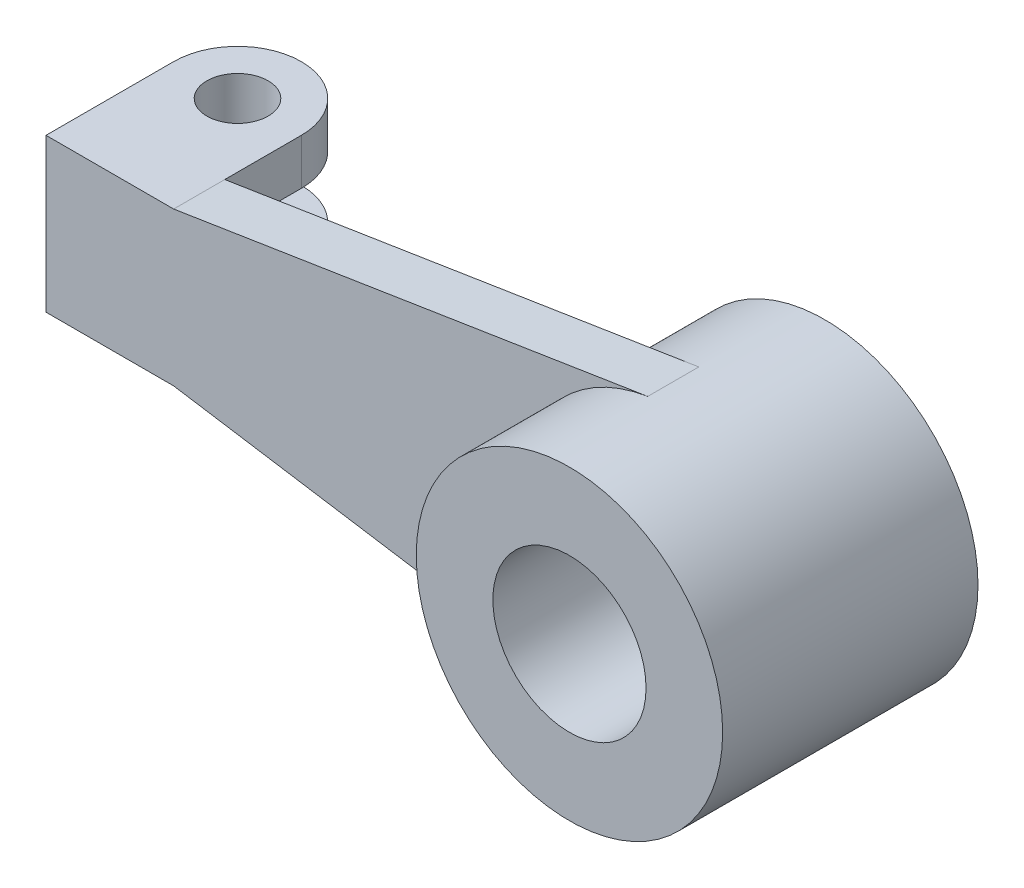
from build123d import *

# Parameters (mm, degrees)
SKETCH1_R           = 30
SKETCH1_R_2         = 15
BOSS_EXTRUDE1_DEPTH = 25
BOSS_EXTRUDE2_DEPTH = 5
SKETCH8_R           = 6
BOSS_EXTRUDE3_DEPTH = 9


with BuildPart() as part:
    # Sketch1 → Boss-Extrude1 (new body, symmetric)
    with BuildSketch(Plane.XY):
        Circle(SKETCH1_R)
        Circle(SKETCH1_R_2, mode=Mode.SUBTRACT)
    extrude(amount=BOSS_EXTRUDE1_DEPTH, both=True)

    # Sketch3 → Boss-Extrude2 (add, symmetric)
    with BuildSketch(Plane.XY):
        with BuildLine():
            Line((-122.5, -15), (-122.5, 15))
            Line((-122.5, 15), (-97.5, 15))
            Line((-97.5, 15), (-4.671688756, 29.634023084))
            ThreePointArc((-4.671688756, 29.634023084), (-30, 0), (-4.671688756, -29.634023084))
            Line((-4.671688756, -29.634023084), (-97.5, -15))
            Line((-97.5, -15), (-122.5, -15))
        make_face()
    extrude(amount=BOSS_EXTRUDE2_DEPTH, both=True)

    # Sketch8 → Boss-Extrude3 (add)
    with BuildSketch(Plane(origin=(0, 15, 0), x_dir=(1, 0, 0), z_dir=(0, 1, 0))):
        with BuildLine():
            Line((-122.5, 5), (-122.5, 20))
            ThreePointArc((-122.5, 20), (-110, 32.5), (-97.5, 20))
            Line((-97.5, 20), (-97.5, 5))
            Line((-97.5, 5), (-122.5, 5))
        make_face()
        with Locations(Location((-110, 20, 0), (0, 0, 180))):  # turned: the seam where the file's is
            Circle(SKETCH8_R, mode=Mode.SUBTRACT)
    boss_extrude3 = extrude(amount=-BOSS_EXTRUDE3_DEPTH)

    # Mirror1: Boss-Extrude3 across plane
    add(boss_extrude3.mirror(Plane.ZX))


solid = part.part
